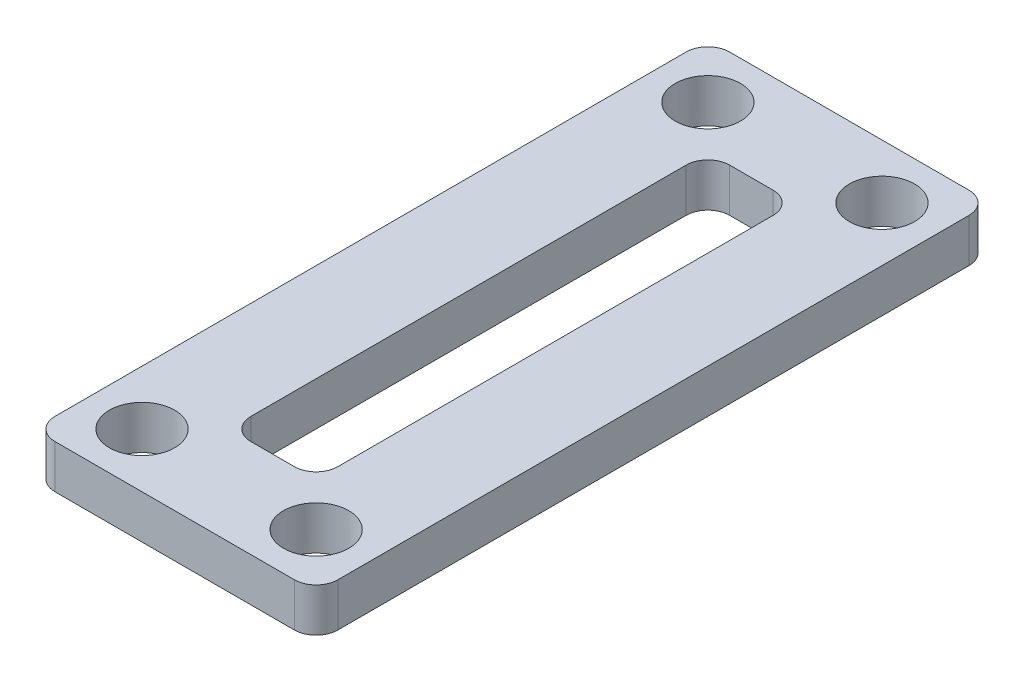
from build123d import *

# Parameters (mm, degrees)
SKETCH1_R           = 1.4
BOSS_EXTRUDE2_DEPTH = 5.5
FILLET2_R           = 1
SKETCH2_R           = 1.5
CUT_EXTRUDE1_DEPTH  = 10
SKETCH3_R           = 36.045042524
CUT_EXTRUDE2_DEPTH  = 0.5
SKETCH4_R           = 41.346922652
CUT_EXTRUDE3_DEPTH  = 1
SKETCH5_R           = 64.87410788
CUT_EXTRUDE4_DEPTH  = 2


with BuildPart() as part:
    # Sketch1 → Boss-Extrude2 (new body)
    with BuildSketch(Plane(origin=(0, 0, 0), x_dir=(1, 0, 0), z_dir=(0, 1, 0))):
        Polygon((4, -2.5), (-2.5, -2.5), (-2.5, 28.5), (10.5, 28.5), (10.5, -2.5), align=None)
        with Locations((8, 26)):
            Circle(SKETCH1_R, mode=Mode.SUBTRACT)
        with Locations((0, 26)):
            Circle(SKETCH1_R, mode=Mode.SUBTRACT)
        with Locations((8, 0)):
            Circle(SKETCH1_R, mode=Mode.SUBTRACT)
        Circle(SKETCH1_R, mode=Mode.SUBTRACT)
        Polygon((4, 2), (2, 2), (2, 24), (6, 24), (6, 2), align=None, mode=Mode.SUBTRACT)
    extrude(amount=BOSS_EXTRUDE2_DEPTH)

    # Fillet2
    fillet2_edges = [part.edges().sort_by_distance(p)[0] for p in [
        (6, 2.75, -24),
        (2, 2.75, -24),
        (2, 2.75, -2),
        (6, 2.75, -2),
        (-2.5, 2.75, 2.5),
        (-2.5, 2.75, -28.5),
        (10.5, 2.75, -28.5),
        (10.5, 2.75, 2.5),
    ]]
    fillet(fillet2_edges, radius=FILLET2_R)

    # Sketch2 → Cut-Extrude1 (cut)
    with BuildSketch(Plane(origin=(0, 5.5, 0), x_dir=(1, 0, 0), z_dir=(0, 1, 0))):
        with Locations((0, 26)):
            Circle(SKETCH2_R)
        with Locations((8, 26)):
            Circle(SKETCH2_R)
        with Locations((8, 0)):
            Circle(SKETCH2_R)
        Circle(SKETCH2_R)
    extrude(amount=-CUT_EXTRUDE1_DEPTH, mode=Mode.SUBTRACT)

    # Sketch3 → Cut-Extrude2 (cut)
    with BuildSketch(Plane(origin=(0, 5.5, 0), x_dir=(1, 0, 0), z_dir=(0, 1, 0))):
        Circle(SKETCH3_R)
    extrude(amount=-CUT_EXTRUDE2_DEPTH, mode=Mode.SUBTRACT)

    # Sketch4 → Cut-Extrude3 (cut)
    with BuildSketch(Plane(origin=(0, 5, 0), x_dir=(1, 0, 0), z_dir=(0, 1, 0))):
        Circle(SKETCH4_R)
    extrude(amount=-CUT_EXTRUDE3_DEPTH, mode=Mode.SUBTRACT)

    # Sketch5 → Cut-Extrude4 (cut)
    with BuildSketch(Plane(origin=(0, 4, 0), x_dir=(1, 0, 0), z_dir=(0, 1, 0))):
        Circle(SKETCH5_R)
    extrude(amount=-CUT_EXTRUDE4_DEPTH, mode=Mode.SUBTRACT)


solid = part.part
